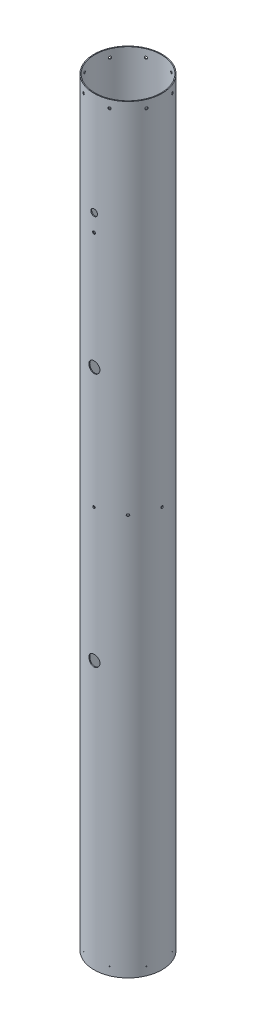
from build123d import *

# Parameters (mm, degrees)
SKIZZE1_R                       = 61.5
SKIZZE1_R_2                     = 60
K_RPERROHR_DEPTH                = 1370
CUT_EXTRUDE1_REACH              = 1379.726
CUT_EXTRUDE1_END_RADIUS         = 60
SKETCH1_R                       = 0.75
SKETCH1_R_2                     = 2.25
CIRPATTERN1_COUNT               = 8
CUT_EXTRUDE3_REACH              = 1378.885
CUT_EXTRUDE3_END_RADIUS         = 60
SKETCH3_R                       = 2.25
CIRPATTERN2_COUNT               = 8
CUT_EXTRUDE2_REACH              = 1378.885
CUT_EXTRUDE2_END_RADIUS         = 60
SKETCH2_R                       = 10
SKETCH2_R_2                     = 2.5
SKETCH4_R                       = 6
CUT_EXTRUDE4_DEPTH              = 1377.884617648
CUT_EXTRUDE5_REACH              = 1378.885
CUT_EXTRUDE5_END_RADIUS         = 60
SKETCH5_R                       = 4
SKIZZE2_R                       = 61.5
SKIZZE2_R_2                     = 60
AUFSATZ_LINEAR_AUSTRAGEN1_DEPTH = 2.35


with BuildPart() as part:
    # Skizze1 → Körperrohr (new body)
    with BuildSketch(Plane(origin=(0, 0, 0), x_dir=(1, 0, 0), z_dir=(0, 1, 0))):
        Circle(SKIZZE1_R)
        Circle(SKIZZE1_R_2, mode=Mode.SUBTRACT)
    extrude(amount=K_RPERROHR_DEPTH)

    # Cut-Extrude1: up to this cylinder (the profile starts outside it)
    cut_extrude1_end = Plane(origin=(0, 684.325, 0), z_dir=(0, -1, 0)) * Cylinder(CUT_EXTRUDE1_END_RADIUS, 4223.802, mode=Mode.PRIVATE)
    # Sketch1 → Cut-Extrude1 (cut, up to the surface)
    with BuildSketch(Plane(origin=(-23.53503109, 0, 56.818591249), x_dir=(-0.9238795325112865, 0, -0.3826834323650906), z_dir=(0.3826834323650906, 0, -0.9238795325112865)), mode=Mode.PRIVATE) as cut_extrude1_sk1:
        with Locations(Location((0, 12.65, 0), (0, 0, 180))):
            Circle(SKETCH1_R)
    cut_extrude1_tool1 = extrude(cut_extrude1_sk1.sketch, amount=CUT_EXTRUDE1_REACH, mode=Mode.PRIVATE) - cut_extrude1_end
    # Sketch1 → Cut-Extrude1 (cut, up to the surface)
    with BuildSketch(Plane(origin=(-23.53503109, 0, 56.818591249), x_dir=(-0.9238795325112865, 0, -0.3826834323650906), z_dir=(0.3826834323650906, 0, -0.9238795325112865)), mode=Mode.PRIVATE) as cut_extrude1_sk2:
        with Locations(Location((0, 1356, 0), (0, 0, 180))):
            Circle(SKETCH1_R_2)
    cut_extrude1_tool2 = extrude(cut_extrude1_sk2.sketch, amount=CUT_EXTRUDE1_REACH, mode=Mode.PRIVATE) - cut_extrude1_end
    cut_extrude1 = cut_extrude1_tool1.solids().sort_by_distance((-23.535031, 12.65, 56.818591))[0] + cut_extrude1_tool2.solids().sort_by_distance((-23.535031, 1356, 56.818591))[0]
    add(cut_extrude1, mode=Mode.SUBTRACT)

    # CirPattern1: Cut-Extrude1 ×8 about axis
    cirpattern1_axis = Axis((0, 1370, 0), (0, -1, 0))
    for i in range(1, CIRPATTERN1_COUNT):
        add(cut_extrude1.rotate(cirpattern1_axis, i * 360 / CIRPATTERN1_COUNT), mode=Mode.SUBTRACT)

    # Cut-Extrude3: up to this cylinder (the profile starts outside it)
    cut_extrude3_end = Plane(origin=(0, 722.3, 0), z_dir=(0, -1, 0)) * Cylinder(CUT_EXTRUDE3_END_RADIUS, 2878.77, mode=Mode.PRIVATE)
    # Sketch3 → Cut-Extrude3 (cut, up to the surface)
    with BuildSketch(Plane(origin=(61.5, 0, 0), x_dir=(0, 0, -1), z_dir=(1, 0, 0)), mode=Mode.PRIVATE) as cut_extrude3_sk1:
        with Locations((0, 722.3)):
            Circle(SKETCH3_R)
    cut_extrude3_tool1 = extrude(cut_extrude3_sk1.sketch, amount=-CUT_EXTRUDE3_REACH, mode=Mode.PRIVATE) - cut_extrude3_end
    cut_extrude3 = cut_extrude3_tool1.solids().sort_by_distance((61.5, 722.3, 0))[0]
    add(cut_extrude3, mode=Mode.SUBTRACT)

    # CirPattern2: Cut-Extrude3 ×8 about axis
    cirpattern2_axis = Axis((0, 1370, 0), (0, -1, 0))
    for i in range(1, CIRPATTERN2_COUNT):
        add(cut_extrude3.rotate(cirpattern2_axis, i * 360 / CIRPATTERN2_COUNT), mode=Mode.SUBTRACT)

    # Cut-Extrude2: up to this cylinder (the profile starts outside it)
    cut_extrude2_end = Plane(origin=(0, 817, 0), z_dir=(0, -1, 0)) * Cylinder(CUT_EXTRUDE2_END_RADIUS, 3548.77, mode=Mode.PRIVATE)
    # Sketch2 → Cut-Extrude2 (cut, up to the surface)
    with BuildSketch(Plane.XY.offset(61.5), mode=Mode.PRIVATE) as cut_extrude2_sk1:
        with Locations((0, 482)):
            Circle(SKETCH2_R)
    cut_extrude2_tool1 = extrude(cut_extrude2_sk1.sketch, amount=-CUT_EXTRUDE2_REACH, mode=Mode.PRIVATE) - cut_extrude2_end
    add(cut_extrude2_tool1.solids().sort_by_distance((0, 482, 61.5))[0], mode=Mode.SUBTRACT)
    # Sketch2 → Cut-Extrude2 (cut, up to the surface)
    with BuildSketch(Plane.XY.offset(61.5), mode=Mode.PRIVATE) as cut_extrude2_sk2:
        with Locations((0, 941.3)):
            Circle(SKETCH2_R)
    cut_extrude2_tool2 = extrude(cut_extrude2_sk2.sketch, amount=-CUT_EXTRUDE2_REACH, mode=Mode.PRIVATE) - cut_extrude2_end
    add(cut_extrude2_tool2.solids().sort_by_distance((0, 941.3, 61.5))[0], mode=Mode.SUBTRACT)
    # Sketch2 → Cut-Extrude2 (cut, up to the surface)
    with BuildSketch(Plane.XY.offset(61.5), mode=Mode.PRIVATE) as cut_extrude2_sk3:
        with Locations((0, 1152)):
            Circle(SKETCH2_R_2)
    cut_extrude2_tool3 = extrude(cut_extrude2_sk3.sketch, amount=-CUT_EXTRUDE2_REACH, mode=Mode.PRIVATE) - cut_extrude2_end
    add(cut_extrude2_tool3.solids().sort_by_distance((0, 1152, 61.5))[0], mode=Mode.SUBTRACT)

    # Sketch4 → Cut-Extrude4 (cut, through all)
    with BuildSketch(Plane.XY.offset(61.5)):
        with Locations((0, 1183.43)):
            Circle(SKETCH4_R)
    extrude(amount=-CUT_EXTRUDE4_DEPTH, mode=Mode.SUBTRACT)

    # Cut-Extrude5: up to this cylinder (the profile starts outside it)
    cut_extrude5_end = Plane(origin=(0, 497, 0), z_dir=(0, -1, 0)) * Cylinder(CUT_EXTRUDE5_END_RADIUS, 2878.77, mode=Mode.PRIVATE)
    # Sketch5 → Cut-Extrude5 (cut, up to the surface)
    with BuildSketch(Plane.ZY.offset(61.5), mode=Mode.PRIVATE) as cut_extrude5_sk1:
        with Locations((0, 497)):
            Circle(SKETCH5_R)
    cut_extrude5_tool1 = extrude(cut_extrude5_sk1.sketch, amount=-CUT_EXTRUDE5_REACH, mode=Mode.PRIVATE) - cut_extrude5_end
    add(cut_extrude5_tool1.solids().sort_by_distance((-61.5, 497, 0))[0], mode=Mode.SUBTRACT)

    # Skizze2 → Aufsatz-Linear austragen1 (add)
    with BuildSketch(Plane.XZ):
        with Locations(Location((0, 0, 0), (0, 0, 270))):
            Circle(SKIZZE2_R)
        with Locations(Location((0, 0, 0), (0, 0, 270))):
            Circle(SKIZZE2_R_2, mode=Mode.SUBTRACT)
    extrude(amount=AUFSATZ_LINEAR_AUSTRAGEN1_DEPTH)


solid = part.part
